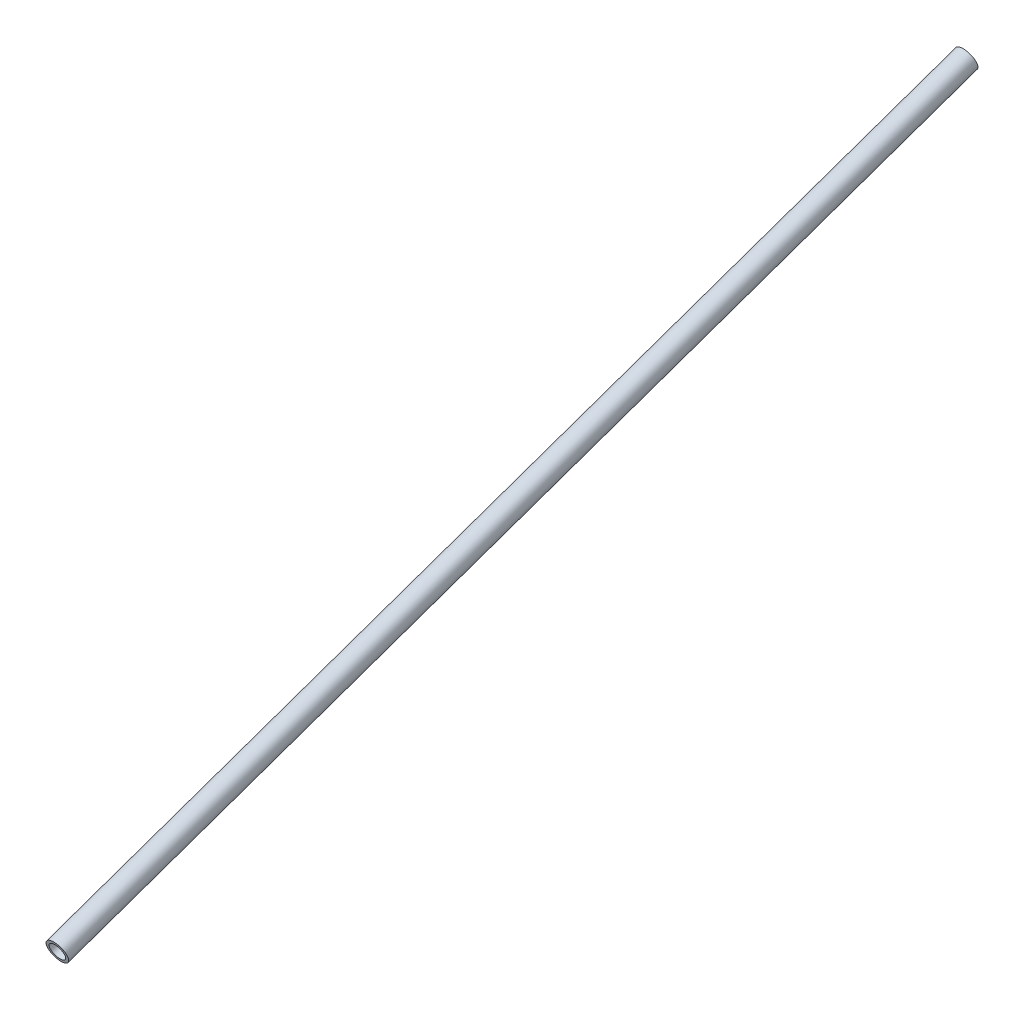
from build123d import *

# Parameters (mm, degrees)
SKETCH1_R                               = 9.525
SKETCH1_R_2                             = 6.985
PIPE_STANDARD_S40_PIPE_1_SCH_40_1_DEPTH = 851.02592632


with BuildPart() as part:
    # Sketch1 → Pipe standard s40 PIPE 1 SCH 40(1) (new body)
    with BuildSketch(Plane(origin=(0, 47.199071849, -31.408390512), x_dir=(0, 0.9435931623759566, 0.33110714869561775), z_dir=(0, 0.33110714869561775, -0.9435931623759566))):
        Circle(SKETCH1_R)
        Circle(SKETCH1_R_2, mode=Mode.SUBTRACT)
    extrude(amount=PIPE_STANDARD_S40_PIPE_1_SCH_40_1_DEPTH)


solid = part.part
